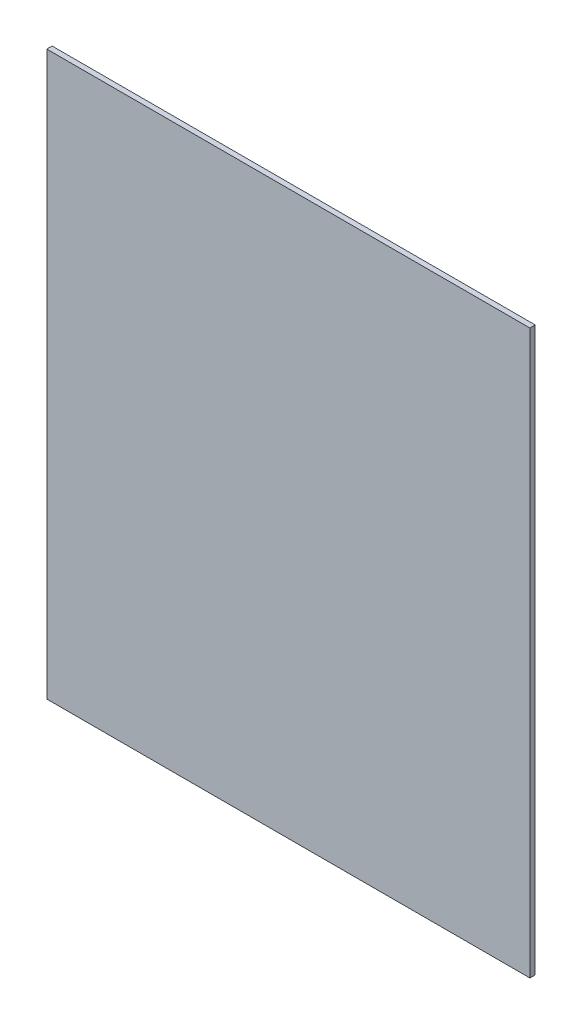
from build123d import *

# Parameters (mm, degrees)
SKETCH3_W           = 909.759108312
SKETCH3_H           = 1060
BOSS_EXTRUDE1_DEPTH = 10


with BuildPart() as part:
    # Sketch3 → Boss-Extrude1 (new body)
    with BuildSketch(Plane.XY):
        with Locations((-9564.395420172, 8991.148370734)):
            Rectangle(SKETCH3_W, SKETCH3_H)
    extrude(amount=BOSS_EXTRUDE1_DEPTH)


solid = part.part
